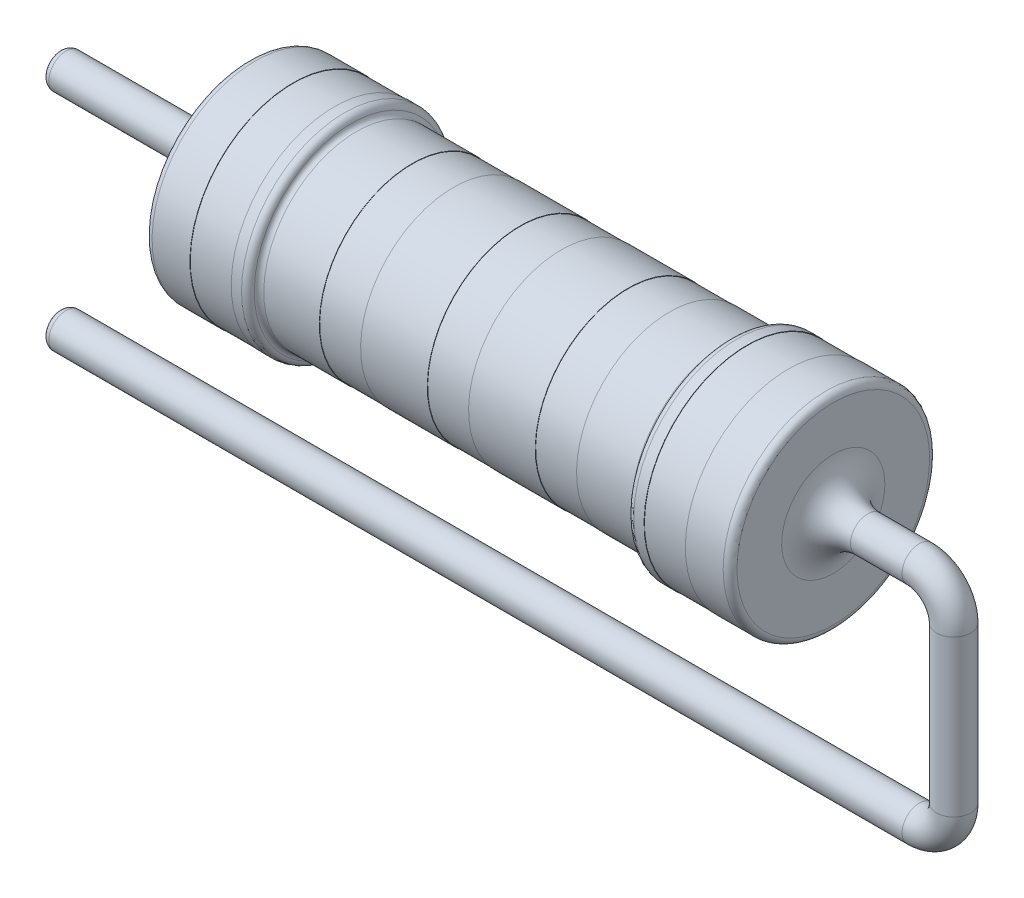
from build123d import *

# Parameters (mm, degrees)
FILLET1_R = 0.2
FILLET2_R = 0.15
SKETCH2_R = 0.5
SKETCH3_R = 0.5
FILLET7_R = 0.2
FILLET8_R = 1


with BuildPart() as part:
    # Sketch1 → Revolve1 (revolve)
    with BuildSketch(Plane.XY):
        Polygon((-8.5, 0), (8.5, 0), (8.5, -3), (7.2, -3), (7.2, -2.99), (6, -2.99), (6, -3), (5.5, -3), (5.5, -2.7), (3.738022236, -2.7), (3.738022236, -2.69), (2.538022236, -2.69), (2.538022236, -2.7), (0.6, -2.7), (0.6, -2.69), (-0.6, -2.69), (-0.6, -2.7), (-2.538022236, -2.7), (-2.538022236, -2.69), (-3.738022236, -2.69), (-3.738022236, -2.7), (-5.5, -2.7), (-5.5, -3), (-6, -3), (-6, -2.99), (-7.2, -2.99), (-7.2, -3), (-8.5, -3), align=None)
    revolve(axis=Axis((-8.5, 0, 0), (1, 0, 0)))

    # Fillet1
    fillet1_edges = [part.edges().sort_by_distance(p)[0] for p in [
        (-8.5, 3, 0),
        (-5.5, 3, 0),
        (5.5, 3, 0),
        (8.5, 3, 0),
    ]]
    fillet(fillet1_edges, radius=FILLET1_R)

    # Fillet2
    fillet2_edges = [part.edges().sort_by_distance(p)[0] for p in [
        (-5.5, 2.7, 0),
        (5.5, 2.7, 0),
    ]]
    fillet(fillet2_edges, radius=FILLET2_R)

    # Sweep1: sweep along a curve in space
    with BuildLine() as sweep1_path:
        Line((8.5, 0, 0), (11, 0, 0))
        ThreePointArc((12, -1, 0), (11.707106781, -0.292893219, 0), (11, 0, 0))
        Line((12, -1, 0), (12, -5.530002448, 0))
        ThreePointArc((11, -6.530002448, 0), (11.707106781, -6.237109229, 0), (12, -5.530002448, 0))
        Line((11, -6.530002448, 0), (-14, -6.530002448, 0))
    # Sketch2 → Sweep1 (sweep)
    with BuildSketch(Plane(origin=(8.5, 0, 0), x_dir=(0, 0, -1), z_dir=(1, 0, 0))):
        Circle(SKETCH2_R)
    sweep(path=sweep1_path.line)

    # Sweep2: sweep along a curve in space
    with BuildLine() as sweep2_path:
        Line((-8.5, 0, 0), (-14, 0, 0))
    # Sketch3 → Sweep2 (sweep)
    with BuildSketch(Plane.ZY.offset(8.5)):
        Circle(SKETCH3_R)
    sweep(path=sweep2_path.line)

    # Fillet7
    fillet7_edges = [part.edges().sort_by_distance(p)[0] for p in [
        (-14, -6.530002448, 0.5),
        (-14, 0, -0.5),
    ]]
    fillet(fillet7_edges, radius=FILLET7_R)

    # Fillet8
    fillet8_edges = [part.edges().sort_by_distance(p)[0] for p in [
        (8.5, 0, 0.5),
        (-8.5, 0, -0.5),
    ]]
    fillet(fillet8_edges, radius=FILLET8_R)


solid = part.part
